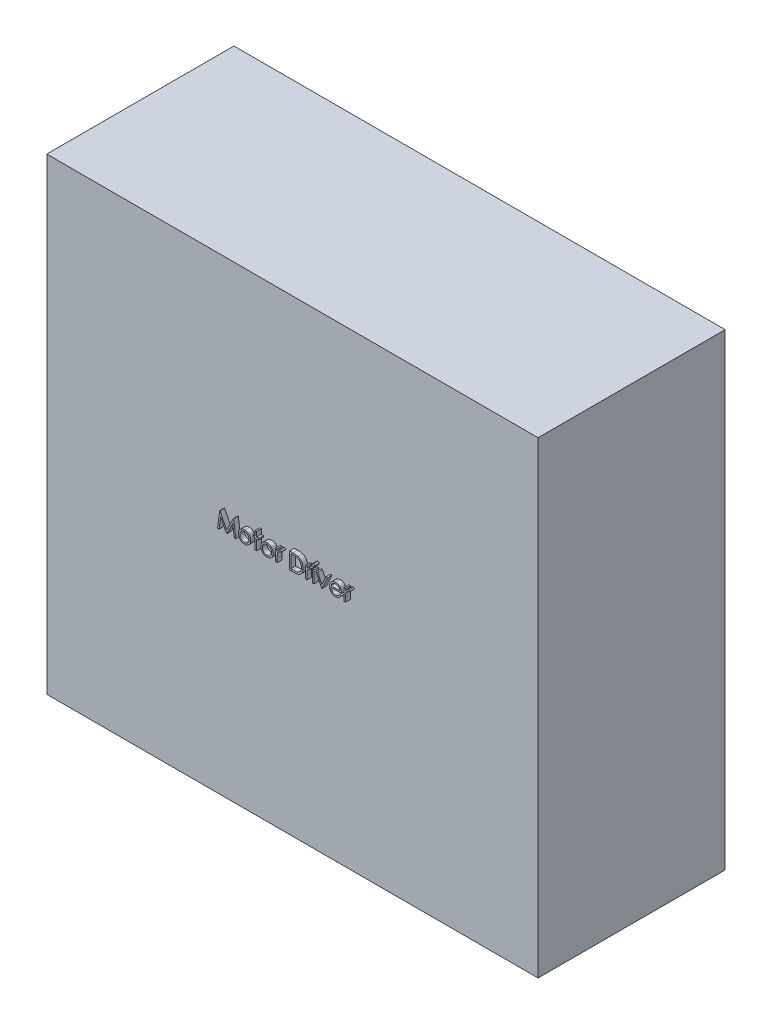
from build123d import *

# Parameters (mm, degrees)
SKETCH1_W           = 105
SKETCH1_H           = 100
BOSS_EXTRUDE1_DEPTH = 40
SKETCH6_W           = 0.314102564
SKETCH6_H           = 2.557692308
BOSS_EXTRUDE2_DEPTH = 1


with BuildPart() as part:
    # Sketch1 → Boss-Extrude1 (new body)
    with BuildSketch(Plane.XY):
        Rectangle(SKETCH1_W, SKETCH1_H)
    extrude(amount=BOSS_EXTRUDE1_DEPTH)

    # Sketch6 → Boss-Extrude2 (add)
    with BuildSketch(Plane.XY.offset(40)):
        Polygon((-14.999928936, -0.016220885), (-14.537889673, 3.483779115), (-14.493017878, 3.483779115), (-13.048005859, 0.611984244), (-11.606499449, 3.483779115), (-11.560926532, 3.483779115), (-11.096082782, -0.016220885), (-11.41158759, -0.016220885), (-11.746723808, 2.502208603), (-13.010145282, -0.016220885), (-13.080958583, -0.016220885), (-14.34928791, 2.507817577), (-14.683723006, -0.016220885), align=None)
        with BuildLine():
            add(Edge.make_bspline(
                [(-9.232501051, 2.586343218), (-9.184509779, 2.585321327), (-9.090410621, 2.583317648), (-8.952602735, 2.561902682), (-8.821057599, 2.529155318), (-8.695271407, 2.483883756), (-8.576855112, 2.423201805), (-8.464083867, 2.350792514), (-8.357266859, 2.265009921), (-8.293243829, 2.198651852), (-8.260746244, 2.164969019)],
                knots=[0, 0, 0, 0, 0.000143868, 0.000282091, 0.000417278, 0.000550139, 0.000682145, 0.000815559, 0.000951665, 0.001091969, 0.001091969, 0.001091969, 0.001091969], degree=3))
            add(Edge.make_bspline(
                [(-8.260746244, 2.164969019), (-8.23276429, 2.132755033), (-8.177341909, 2.068950491), (-8.106276191, 1.965494878), (-8.04505463, 1.858354778), (-7.995991669, 1.746107451), (-7.957306646, 1.62973278), (-7.929840949, 1.508830769), (-7.913504015, 1.383668421), (-7.911301048, 1.298664583), (-7.910185346, 1.255614051)],
                knots=[0, 0, 0, 0, 0.000127922, 0.000253368, 0.000375813, 0.000497617, 0.000620225, 0.000743195, 0.000869033, 0.000998161, 0.000998161, 0.000998161, 0.000998161], degree=3))
            add(Edge.make_bspline(
                [(-7.910185346, 1.255614051), (-7.911166684, 1.212313994), (-7.913105852, 1.12675106), (-7.931449468, 1.000731694), (-7.959980554, 0.878536872), (-8.000812392, 0.760678178), (-8.053170502, 0.646795351), (-8.117061189, 0.537385801), (-8.192932806, 0.432233668), (-8.278936803, 0.33223183), (-8.373988679, 0.240065615), (-8.477104827, 0.159737345), (-8.586258861, 0.090915821), (-8.702902215, 0.035479405), (-8.825969701, -0.008230295), (-8.955726769, -0.038930311), (-9.09197184, -0.057491995), (-9.184999061, -0.059875568), (-9.232501051, -0.06109268)],
                knots=[0, 0, 0, 0, 0.000129829, 0.000256548, 0.000381202, 0.000505812, 0.000630045, 0.000756669, 0.000885282, 0.001018518, 0.001151902, 0.001281775, 0.001409974, 0.001538236, 0.001668405, 0.001801048, 0.001937587, 0.002080055, 0.002080055, 0.002080055, 0.002080055], degree=3))
            add(Edge.make_bspline(
                [(-9.232501051, -0.06109268), (-9.280235771, -0.059871483), (-9.373726631, -0.057479709), (-9.510452613, -0.039002426), (-9.640442231, -0.008244444), (-9.76367083, 0.035623049), (-9.880815677, 0.090917593), (-9.990602174, 0.159529283), (-10.093802089, 0.240089438), (-10.188874074, 0.332225375), (-10.274872679, 0.432235331), (-10.350745687, 0.53738537), (-10.414636014, 0.646795463), (-10.466994218, 0.760678148), (-10.50782603, 0.87853688), (-10.536357123, 1.000731692), (-10.554700738, 1.126751061), (-10.556639906, 1.212313994), (-10.557621244, 1.255614051)],
                knots=[0, 0, 0, 0, 0.000143168, 0.000280402, 0.000413045, 0.000543214, 0.000672108, 0.000800903, 0.000930775, 0.00106416, 0.001197395, 0.001326009, 0.001452632, 0.001576866, 0.001701476, 0.00182613, 0.001952849, 0.002082678, 0.002082678, 0.002082678, 0.002082678], degree=3))
            add(Edge.make_bspline(
                [(-10.557621244, 1.255614051), (-10.556497933, 1.298430597), (-10.554273972, 1.3832), (-10.537953463, 1.50812706), (-10.510594906, 1.628824449), (-10.47186351, 1.744749925), (-10.422348319, 1.856505361), (-10.361987031, 1.963910192), (-10.290196398, 2.066897993), (-10.234994447, 2.130620073), (-10.207060346, 2.162865654)],
                knots=[0, 0, 0, 0, 0.000128428, 0.000254265, 0.000377235, 0.000499178, 0.000620341, 0.000743397, 0.000868267, 0.000996189, 0.000996189, 0.000996189, 0.000996189], degree=3))
            add(Edge.make_bspline(
                [(-10.207060346, 2.162865654), (-10.174611755, 2.196840593), (-10.110795891, 2.263658289), (-10.003447164, 2.349190813), (-9.890953343, 2.423106887), (-9.771228416, 2.482583103), (-9.645545558, 2.52942162), (-9.513326316, 2.561987135), (-9.3750508, 2.58324049), (-9.280491179, 2.585298668), (-9.232501051, 2.586343218)],
                knots=[0, 0, 0, 0, 0.000140798, 0.000276904, 0.000410699, 0.000543958, 0.000677061, 0.000812248, 0.000951858, 0.001095726, 0.001095726, 0.001095726, 0.001095726], degree=3))
        make_face()
        with BuildLine():
            add(Edge.make_bspline(
                [(-9.233903295, 2.272240654), (-9.267840906, 2.271276062), (-9.334840035, 2.26937178), (-9.43345962, 2.254887875), (-9.528399774, 2.231940371), (-9.619840618, 2.199336315), (-9.70747379, 2.157237416), (-9.791383193, 2.105529055), (-9.871815632, 2.044896099), (-9.947197696, 1.975433427), (-10.016380008, 1.899554433), (-10.076857985, 1.818706074), (-10.128283091, 1.734199728), (-10.17112325, 1.645947516), (-10.203030438, 1.553055103), (-10.22620346, 1.456574471), (-10.240673701, 1.356309055), (-10.24256008, 1.288148037), (-10.24351868, 1.253510686)],
                knots=[0, 0, 0, 0, 0.000101781, 0.000200935, 0.000298373, 0.000394396, 0.000491609, 0.000589491, 0.000689611, 0.000793323, 0.000896562, 0.000997243, 0.001095722, 0.001192936, 0.001290943, 0.001389744, 0.001490285, 0.001594167, 0.001594167, 0.001594167, 0.001594167], degree=3))
            add(Edge.make_bspline(
                [(-10.24351868, 1.253510686), (-10.241911856, 1.208758659), (-10.238722611, 1.119934253), (-10.212787375, 0.989123131), (-10.169401095, 0.863541278), (-10.110813815, 0.743924892), (-10.037407597, 0.633252614), (-9.95092053, 0.53458113), (-9.85228083, 0.449395319), (-9.74266433, 0.378714473), (-9.624310012, 0.322554717), (-9.499053691, 0.282755742), (-9.368412996, 0.256884049), (-9.279132265, 0.254312575), (-9.233903295, 0.253009885)],
                knots=[0, 0, 0, 0, 0.000134178, 0.000266319, 0.000398243, 0.00053182, 0.000664828, 0.000795487, 0.000924236, 0.001054533, 0.001185628, 0.001316003, 0.001448011, 0.001583547, 0.001583547, 0.001583547, 0.001583547], degree=3))
            add(Edge.make_bspline(
                [(-9.233903295, 0.253009885), (-9.188676926, 0.254320165), (-9.09940133, 0.256906622), (-8.968942153, 0.282625441), (-8.844028181, 0.322729102), (-8.725796794, 0.378651312), (-8.61623019, 0.449663727), (-8.516881069, 0.534100104), (-8.431132458, 0.633513955), (-8.357798853, 0.744071484), (-8.29825211, 0.863355836), (-8.255068909, 0.989146308), (-8.229071323, 1.11992835), (-8.225890494, 1.208756681), (-8.22428791, 1.253510686)],
                knots=[0, 0, 0, 0, 0.000135536, 0.000267545, 0.000397252, 0.000528347, 0.000658644, 0.000787925, 0.000918122, 0.00105113, 0.001185017, 0.001316942, 0.001449082, 0.00158326, 0.00158326, 0.00158326, 0.00158326], degree=3))
            add(Edge.make_bspline(
                [(-8.22428791, 1.253510686), (-8.22524618, 1.288148244), (-8.227131909, 1.356309669), (-8.241606874, 1.456572123), (-8.264762414, 1.553063719), (-8.296734031, 1.645915723), (-8.339388045, 1.734428227), (-8.391804838, 1.818457954), (-8.452035863, 1.8998345), (-8.522052984, 1.975188141), (-8.597356362, 2.044923178), (-8.6778214, 2.105552567), (-8.761606379, 2.157010162), (-8.848984961, 2.199696403), (-8.940437529, 2.231643743), (-9.035244658, 2.255020375), (-9.133443468, 2.269310571), (-9.200202511, 2.271257713), (-9.233903295, 2.272240654)],
                knots=[0, 0, 0, 0, 0.000103882, 0.000204424, 0.000303225, 0.000401232, 0.000498445, 0.000597291, 0.000697972, 0.000801684, 0.000905395, 0.001005516, 0.001103397, 0.001199979, 0.001296663, 0.00139342, 0.001492573, 0.001593654, 0.001593654, 0.001593654, 0.001593654], degree=3))
        make_face(mode=Mode.SUBTRACT)
        Polygon((-6.967877654, 3.573522705), (-6.65377509, 3.573522705), (-6.65377509, 2.541471423), (-6.205057141, 2.541471423), (-6.205057141, 2.227368859), (-6.65377509, 2.227368859), (-6.65377509, -0.016220885), (-6.967877654, -0.016220885), (-6.967877654, 2.227368859), (-7.416595603, 2.227368859), (-7.416595603, 2.541471423), (-6.967877654, 2.541471423), align=None)
        with BuildLine():
            add(Edge.make_bspline(
                [(-4.431219, 2.586343218), (-4.383227727, 2.585321327), (-4.28912857, 2.583317648), (-4.151320684, 2.561902682), (-4.019775548, 2.529155318), (-3.893989356, 2.483883756), (-3.77557306, 2.423201805), (-3.662801816, 2.350792514), (-3.555984807, 2.265009921), (-3.491961778, 2.198651852), (-3.459464192, 2.164969019)],
                knots=[0, 0, 0, 0, 0.000143868, 0.000282091, 0.000417278, 0.000550139, 0.000682145, 0.000815559, 0.000951665, 0.001091969, 0.001091969, 0.001091969, 0.001091969], degree=3))
            add(Edge.make_bspline(
                [(-3.459464192, 2.164969019), (-3.431482238, 2.132755033), (-3.376059858, 2.068950491), (-3.304994139, 1.965494878), (-3.243772579, 1.858354778), (-3.194709618, 1.746107451), (-3.156024594, 1.62973278), (-3.128558898, 1.508830769), (-3.112221963, 1.383668421), (-3.110018996, 1.298664583), (-3.108903295, 1.255614051)],
                knots=[0, 0, 0, 0, 0.000127922, 0.000253368, 0.000375813, 0.000497617, 0.000620225, 0.000743195, 0.000869033, 0.000998161, 0.000998161, 0.000998161, 0.000998161], degree=3))
            add(Edge.make_bspline(
                [(-3.108903295, 1.255614051), (-3.109884632, 1.212313994), (-3.111823801, 1.12675106), (-3.130167417, 1.000731694), (-3.158698503, 0.878536872), (-3.199530341, 0.760678178), (-3.25188845, 0.646795351), (-3.315779138, 0.537385801), (-3.391650755, 0.432233668), (-3.477654752, 0.33223183), (-3.572706628, 0.240065615), (-3.675822776, 0.159737345), (-3.78497681, 0.090915821), (-3.901620163, 0.035479405), (-4.02468765, -0.008230295), (-4.154444718, -0.038930311), (-4.290689788, -0.057491995), (-4.38371701, -0.059875568), (-4.431219, -0.06109268)],
                knots=[0, 0, 0, 0, 0.000129829, 0.000256548, 0.000381202, 0.000505812, 0.000630045, 0.000756669, 0.000885282, 0.001018518, 0.001151902, 0.001281775, 0.001409974, 0.001538236, 0.001668405, 0.001801048, 0.001937587, 0.002080055, 0.002080055, 0.002080055, 0.002080055], degree=3))
            add(Edge.make_bspline(
                [(-4.431219, -0.06109268), (-4.47895372, -0.059871483), (-4.572444579, -0.057479709), (-4.709170561, -0.039002426), (-4.83916018, -0.008244444), (-4.962388779, 0.035623049), (-5.079533626, 0.090917593), (-5.189320123, 0.159529283), (-5.292520038, 0.240089438), (-5.387592023, 0.332225375), (-5.473590628, 0.432235331), (-5.549463636, 0.53738537), (-5.613353962, 0.646795463), (-5.665712166, 0.760678148), (-5.706543979, 0.87853688), (-5.735075072, 1.000731692), (-5.753418686, 1.126751061), (-5.755357855, 1.212313994), (-5.756339192, 1.255614051)],
                knots=[0, 0, 0, 0, 0.000143168, 0.000280402, 0.000413045, 0.000543214, 0.000672108, 0.000800903, 0.000930775, 0.00106416, 0.001197395, 0.001326009, 0.001452632, 0.001576866, 0.001701476, 0.00182613, 0.001952849, 0.002082678, 0.002082678, 0.002082678, 0.002082678], degree=3))
            add(Edge.make_bspline(
                [(-5.756339192, 1.255614051), (-5.755215882, 1.298430597), (-5.752991921, 1.3832), (-5.736671412, 1.50812706), (-5.709312855, 1.628824449), (-5.670581459, 1.744749925), (-5.621066268, 1.856505361), (-5.56070498, 1.963910192), (-5.488914347, 2.066897993), (-5.433712396, 2.130620073), (-5.405778295, 2.162865654)],
                knots=[0, 0, 0, 0, 0.000128428, 0.000254265, 0.000377235, 0.000499178, 0.000620341, 0.000743397, 0.000868267, 0.000996189, 0.000996189, 0.000996189, 0.000996189], degree=3))
            add(Edge.make_bspline(
                [(-5.405778295, 2.162865654), (-5.373329704, 2.196840593), (-5.30951384, 2.263658289), (-5.202165112, 2.349190813), (-5.089671291, 2.423106887), (-4.969946365, 2.482583103), (-4.844263507, 2.52942162), (-4.712044265, 2.561987135), (-4.573768749, 2.58324049), (-4.479209128, 2.585298668), (-4.431219, 2.586343218)],
                knots=[0, 0, 0, 0, 0.000140798, 0.000276904, 0.000410699, 0.000543958, 0.000677061, 0.000812248, 0.000951858, 0.001095726, 0.001095726, 0.001095726, 0.001095726], degree=3))
        make_face()
        with BuildLine():
            add(Edge.make_bspline(
                [(-4.432621244, 2.272240654), (-4.466558855, 2.271276062), (-4.533557984, 2.26937178), (-4.632177568, 2.254887875), (-4.727117722, 2.231940371), (-4.818558566, 2.199336315), (-4.906191739, 2.157237416), (-4.990101141, 2.105529055), (-5.070533581, 2.044896099), (-5.145915645, 1.975433427), (-5.215097957, 1.899554433), (-5.275575933, 1.818706074), (-5.32700104, 1.734199728), (-5.369841199, 1.645947516), (-5.401748387, 1.553055103), (-5.424921409, 1.456574471), (-5.43939165, 1.356309055), (-5.441278028, 1.288148037), (-5.442236628, 1.253510686)],
                knots=[0, 0, 0, 0, 0.000101781, 0.000200935, 0.000298373, 0.000394396, 0.000491609, 0.000589491, 0.000689611, 0.000793323, 0.000896562, 0.000997243, 0.001095722, 0.001192936, 0.001290943, 0.001389744, 0.001490285, 0.001594167, 0.001594167, 0.001594167, 0.001594167], degree=3))
            add(Edge.make_bspline(
                [(-5.442236628, 1.253510686), (-5.440629805, 1.208758659), (-5.43744056, 1.119934253), (-5.411505324, 0.989123131), (-5.368119044, 0.863541278), (-5.309531764, 0.743924892), (-5.236125545, 0.633252614), (-5.149638479, 0.53458113), (-5.050998778, 0.449395319), (-4.941382278, 0.378714473), (-4.82302796, 0.322554717), (-4.697771639, 0.282755742), (-4.567130945, 0.256884049), (-4.477850214, 0.254312575), (-4.432621244, 0.253009885)],
                knots=[0, 0, 0, 0, 0.000134178, 0.000266319, 0.000398243, 0.00053182, 0.000664828, 0.000795487, 0.000924236, 0.001054533, 0.001185628, 0.001316003, 0.001448011, 0.001583547, 0.001583547, 0.001583547, 0.001583547], degree=3))
            add(Edge.make_bspline(
                [(-4.432621244, 0.253009885), (-4.387394875, 0.254320165), (-4.298119279, 0.256906622), (-4.167660102, 0.282625441), (-4.04274613, 0.322729102), (-3.924514743, 0.378651312), (-3.814948139, 0.449663727), (-3.715599018, 0.534100104), (-3.629850407, 0.633513955), (-3.556516802, 0.744071484), (-3.496970059, 0.863355836), (-3.453786857, 0.989146308), (-3.427789271, 1.11992835), (-3.424608443, 1.208756681), (-3.423005859, 1.253510686)],
                knots=[0, 0, 0, 0, 0.000135536, 0.000267545, 0.000397252, 0.000528347, 0.000658644, 0.000787925, 0.000918122, 0.00105113, 0.001185017, 0.001316942, 0.001449082, 0.00158326, 0.00158326, 0.00158326, 0.00158326], degree=3))
            add(Edge.make_bspline(
                [(-3.423005859, 1.253510686), (-3.423964129, 1.288148244), (-3.425849858, 1.356309669), (-3.440324823, 1.456572123), (-3.463480362, 1.553063719), (-3.495451979, 1.645915723), (-3.538105993, 1.734428227), (-3.590522786, 1.818457954), (-3.650753812, 1.8998345), (-3.720770933, 1.975188141), (-3.796074311, 2.044923178), (-3.876539349, 2.105552567), (-3.960324327, 2.157010162), (-4.04770291, 2.199696403), (-4.139155478, 2.231643743), (-4.233962607, 2.255020375), (-4.332161417, 2.269310571), (-4.39892046, 2.271257713), (-4.432621244, 2.272240654)],
                knots=[0, 0, 0, 0, 0.000103882, 0.000204424, 0.000303225, 0.000401232, 0.000498445, 0.000597291, 0.000697972, 0.000801684, 0.000905395, 0.001005516, 0.001103397, 0.001199979, 0.001296663, 0.00139342, 0.001492573, 0.001593654, 0.001593654, 0.001593654, 0.001593654], degree=3))
        make_face(mode=Mode.SUBTRACT)
        with BuildLine():
            Line((-2.570441756, 2.541471423), (-2.256339192, 2.541471423))
            Line((-2.256339192, 2.541471423), (-2.256339192, 2.164969019))
            add(Edge.make_bspline(
                [(-2.256339192, 2.164969019), (-2.233150434, 2.200024847), (-2.188802113, 2.267068847), (-2.115089183, 2.355738148), (-2.039585852, 2.429153194), (-1.961930665, 2.487656713), (-1.881552565, 2.531469832), (-1.800215613, 2.563562867), (-1.716640143, 2.582540182), (-1.660478219, 2.585073841), (-1.632340795, 2.586343218)],
                knots=[0, 0, 0, 0, 0.000126023, 0.000241017, 0.000345147, 0.000441342, 0.00053171, 0.000618946, 0.000702978, 0.000787349, 0.000787349, 0.000787349, 0.000787349], degree=3))
            add(Edge.make_bspline(
                [(-1.632340795, 2.586343218), (-1.610514468, 2.585152691), (-1.565605383, 2.582703105), (-1.497622793, 2.565492281), (-1.427579342, 2.538014258), (-1.382436954, 2.512174036), (-1.358903295, 2.498702994)],
                knots=[0, 0, 0, 0, 6.5445e-05, 0.000134658, 0.00020926, 0.000290509, 0.000290509, 0.000290509, 0.000290509], degree=3))
            Line((-1.358903295, 2.498702994), (-1.531379256, 2.226667737))
            add(Edge.make_bspline(
                [(-1.531379256, 2.226667737), (-1.546488278, 2.233408003), (-1.575168092, 2.246202319), (-1.617122658, 2.261344329), (-1.655803995, 2.270260245), (-1.680447554, 2.271610962), (-1.691936148, 2.272240654)],
                knots=[0, 0, 0, 0, 4.9621e-05, 9.4191e-05, 0.00013366, 0.000168129, 0.000168129, 0.000168129, 0.000168129], degree=3))
            add(Edge.make_bspline(
                [(-1.691936148, 2.272240654), (-1.717141881, 2.270560616), (-1.768554271, 2.267133827), (-1.84403877, 2.240195019), (-1.917285976, 2.196669779), (-1.975457638, 2.148398667), (-2.020499891, 2.10185087), (-2.052640117, 2.061202467), (-2.082122864, 2.015623836), (-2.110293084, 1.965894152), (-2.135959378, 1.911164306), (-2.159914047, 1.851981093), (-2.18157291, 1.788275964), (-2.193923155, 1.743893444), (-2.200249449, 1.721158923)],
                knots=[0, 0, 0, 0, 7.549e-05, 0.000153978, 0.000237553, 0.000330197, 0.000379784, 0.000431685, 0.000485357, 0.000542493, 0.000603021, 0.000666557, 0.00073396, 0.000804745, 0.000804745, 0.000804745, 0.000804745], degree=3))
            add(Edge.make_bspline(
                [(-2.200249449, 1.721158923), (-2.204981842, 1.700881749), (-2.215463734, 1.655969351), (-2.225655272, 1.580620826), (-2.23572479, 1.491597167), (-2.242821408, 1.388650574), (-2.24939945, 1.272038131), (-2.253109532, 1.141582185), (-2.256212673, 0.997148834), (-2.25629574, 0.896174481), (-2.256339192, 0.843354436)],
                knots=[0, 0, 0, 0, 6.2435e-05, 0.000138289, 0.000227871, 0.000331224, 0.000447781, 0.000578258, 0.000722716, 0.000881171, 0.000881171, 0.000881171, 0.000881171], degree=3))
            Line((-2.256339192, 0.843354436), (-2.256339192, -0.016220885))
            Line((-2.256339192, -0.016220885), (-2.570441756, -0.016220885))
            Line((-2.570441756, -0.016220885), (-2.570441756, 2.541471423))
        make_face()
        with BuildLine():
            Line((0.391096705, -0.016220885), (0.391096705, 3.483779115))
            Line((0.391096705, 3.483779115), (1.097827474, 3.483779115))
            add(Edge.make_bspline(
                [(1.097827474, 3.483779115), (1.159296462, 3.483336545), (1.278054228, 3.482481502), (1.449666675, 3.477060111), (1.608450438, 3.467469645), (1.753883297, 3.453500119), (1.886364509, 3.436347086), (2.005523117, 3.414846681), (2.11197526, 3.389458511), (2.1774447, 3.367813061), (2.208404397, 3.357577192)],
                knots=[0, 0, 0, 0, 0.000184407, 0.000356273, 0.000515031, 0.000661537, 0.000794508, 0.000915664, 0.001024665, 0.001122454, 0.001122454, 0.001122454, 0.001122454], degree=3))
            add(Edge.make_bspline(
                [(2.208404397, 3.357577192), (2.248899137, 3.342146487), (2.328970329, 3.311634993), (2.442977452, 3.254078691), (2.550302814, 3.188865589), (2.651521959, 3.115909727), (2.744322786, 3.033145378), (2.832330682, 2.944088293), (2.911945406, 2.845499952), (2.984853702, 2.739424964), (3.050589362, 2.627112912), (3.10772852, 2.508777804), (3.155182513, 2.385020595), (3.19457574, 2.256185447), (3.225622197, 2.12198907), (3.246804129, 1.982275204), (3.260775119, 1.837596014), (3.26217917, 1.73942155), (3.262891577, 1.689608442)],
                knots=[0, 0, 0, 0, 0.000129935, 0.000256923, 0.000382457, 0.000506429, 0.000630624, 0.000755071, 0.000881654, 0.001010204, 0.001140916, 0.00127168, 0.001403968, 0.001538146, 0.001675568, 0.001816774, 0.001961818, 0.002111216, 0.002111216, 0.002111216, 0.002111216], degree=3))
            add(Edge.make_bspline(
                [(3.262891577, 1.689608442), (3.262262609, 1.646347204), (3.261023163, 1.561096415), (3.249893847, 1.435455519), (3.233717527, 1.313541948), (3.208673329, 1.195936248), (3.178270816, 1.08160803), (3.139306665, 0.971775786), (3.094671169, 0.865431976), (3.04262129, 0.7640145), (2.985479905, 0.667931128), (2.924158162, 0.5773556), (2.858721466, 0.493580378), (2.788545834, 0.416351766), (2.714538117, 0.345786188), (2.636213787, 0.281294172), (2.553370736, 0.224137617), (2.466380013, 0.172070509), (2.372703884, 0.126650154), (2.270568018, 0.088220144), (2.15953684, 0.056373529), (2.039882883, 0.029802633), (1.911399405, 0.00872533), (1.773960439, -0.005401062), (1.627777149, -0.014953995), (1.527397884, -0.015790388), (1.475732122, -0.016220885)],
                knots=[0, 0, 0, 0, 0.000129755, 0.000255696, 0.000378151, 0.000498469, 0.000616165, 0.000732801, 0.000847787, 0.000961923, 0.00107447, 0.001182981, 0.001289856, 0.001393094, 0.001495748, 0.001596383, 0.00169713, 0.001797413, 0.001900265, 0.002008995, 0.002124372, 0.002246504, 0.002376522, 0.002514729, 0.002660846, 0.00281582, 0.00281582, 0.00281582, 0.00281582], degree=3))
            Line((1.475732122, -0.016220885), (0.391096705, -0.016220885))
        make_face()
        with BuildLine():
            Line((0.705199269, 0.342753474), (1.106942058, 0.342753474))
            add(Edge.make_bspline(
                [(1.106942058, 0.342753474), (1.164670428, 0.343001571), (1.275703227, 0.343478751), (1.435361224, 0.347665954), (1.581240621, 0.354507891), (1.71336213, 0.364082969), (1.831651154, 0.376751584), (1.936354904, 0.390876487), (2.027130162, 0.408473938), (2.082059599, 0.424424897), (2.107442859, 0.431795942)],
                knots=[0, 0, 0, 0, 0.000173183, 0.000333094, 0.000479096, 0.000611272, 0.000730431, 0.000835931, 0.000928194, 0.001007458, 0.001007458, 0.001007458, 0.001007458], degree=3))
            add(Edge.make_bspline(
                [(2.107442859, 0.431795942), (2.139391221, 0.4430475), (2.202524859, 0.465281874), (2.293405944, 0.505839535), (2.378162949, 0.553881605), (2.458272974, 0.607283879), (2.53259963, 0.667929881), (2.602023746, 0.734500869), (2.666405547, 0.807335645), (2.725079855, 0.886343806), (2.777588159, 0.971033602), (2.823059389, 1.060572435), (2.86291092, 1.153979246), (2.894189513, 1.252688404), (2.918705097, 1.355817463), (2.936069785, 1.463373676), (2.94688451, 1.575336958), (2.948145958, 1.651489082), (2.948789013, 1.690309564)],
                knots=[0, 0, 0, 0, 0.000101593, 0.000200759, 0.000298073, 0.000393552, 0.000489254, 0.000585454, 0.000681817, 0.000780535, 0.000880346, 0.000980374, 0.001081551, 0.001184655, 0.001290601, 0.001399295, 0.001511268, 0.001627707, 0.001627707, 0.001627707, 0.001627707], degree=3))
            add(Edge.make_bspline(
                [(2.948789013, 1.690309564), (2.948275725, 1.731243044), (2.947267368, 1.811657229), (2.934593057, 1.929647924), (2.916071502, 2.043128575), (2.889287816, 2.15210677), (2.855156937, 2.256795122), (2.812562295, 2.356614632), (2.763895676, 2.452619501), (2.705992339, 2.542593867), (2.642576746, 2.627686976), (2.572198866, 2.705641892), (2.495976828, 2.776636192), (2.414741978, 2.841775505), (2.326204879, 2.89843918), (2.232451188, 2.949125862), (2.132105517, 2.992141753), (2.062292821, 3.015020616), (2.026813852, 3.026647705)],
                knots=[0, 0, 0, 0, 0.000122746, 0.000241136, 0.000355593, 0.000467485, 0.000577457, 0.000685538, 0.00079278, 0.000899951, 0.001006101, 0.00111085, 0.001214524, 0.001318328, 0.001422759, 0.001529413, 0.00163777, 0.001749741, 0.001749741, 0.001749741, 0.001749741], degree=3))
            add(Edge.make_bspline(
                [(2.026813852, 3.026647705), (1.997462706, 3.034764133), (1.935054116, 3.052021886), (1.833214652, 3.070847258), (1.718599502, 3.087451757), (1.590699801, 3.101509796), (1.449661342, 3.111597118), (1.295375654, 3.119168432), (1.12777605, 3.124275065), (1.011593516, 3.124623772), (0.951293019, 3.124804756)],
                knots=[0, 0, 0, 0, 9.1321e-05, 0.000194173, 0.000310382, 0.000438754, 0.000580072, 0.000734511, 0.000902151, 0.001083046, 0.001083046, 0.001083046, 0.001083046], degree=3))
            Line((0.951293019, 3.124804756), (0.705199269, 3.124804756))
            Line((0.705199269, 3.124804756), (0.705199269, 0.342753474))
        make_face(mode=Mode.SUBTRACT)
        with BuildLine():
            Line((3.801353115, 2.541471423), (4.115455679, 2.541471423))
            Line((4.115455679, 2.541471423), (4.115455679, 2.164969019))
            add(Edge.make_bspline(
                [(4.115455679, 2.164969019), (4.138644438, 2.200024847), (4.182992759, 2.267068847), (4.256705688, 2.355738148), (4.33220902, 2.429153194), (4.409864207, 2.487656713), (4.490242307, 2.531469832), (4.571579259, 2.563562867), (4.655154729, 2.582540182), (4.711316653, 2.585073841), (4.739454077, 2.586343218)],
                knots=[0, 0, 0, 0, 0.000126023, 0.000241017, 0.000345147, 0.000441342, 0.00053171, 0.000618946, 0.000702978, 0.000787349, 0.000787349, 0.000787349, 0.000787349], degree=3))
            add(Edge.make_bspline(
                [(4.739454077, 2.586343218), (4.761280403, 2.585152691), (4.806189489, 2.582703105), (4.874172078, 2.565492281), (4.94421553, 2.538014258), (4.989357917, 2.512174036), (5.012891577, 2.498702994)],
                knots=[0, 0, 0, 0, 6.5445e-05, 0.000134658, 0.00020926, 0.000290509, 0.000290509, 0.000290509, 0.000290509], degree=3))
            Line((5.012891577, 2.498702994), (4.840415615, 2.226667737))
            add(Edge.make_bspline(
                [(4.840415615, 2.226667737), (4.825306594, 2.233408003), (4.79662678, 2.246202319), (4.754672213, 2.261344329), (4.715990877, 2.270260245), (4.691347318, 2.271610962), (4.679858724, 2.272240654)],
                knots=[0, 0, 0, 0, 4.9621e-05, 9.4191e-05, 0.00013366, 0.000168129, 0.000168129, 0.000168129, 0.000168129], degree=3))
            add(Edge.make_bspline(
                [(4.679858724, 2.272240654), (4.654652991, 2.270560616), (4.603240601, 2.267133827), (4.527756101, 2.240195019), (4.454508896, 2.196669779), (4.396337234, 2.148398667), (4.351294981, 2.10185087), (4.319154755, 2.061202467), (4.289672008, 2.015623836), (4.261501788, 1.965894152), (4.235835494, 1.911164306), (4.211880824, 1.851981093), (4.190221961, 1.788275964), (4.177871717, 1.743893444), (4.171545423, 1.721158923)],
                knots=[0, 0, 0, 0, 7.549e-05, 0.000153978, 0.000237553, 0.000330197, 0.000379784, 0.000431685, 0.000485357, 0.000542493, 0.000603021, 0.000666557, 0.00073396, 0.000804745, 0.000804745, 0.000804745, 0.000804745], degree=3))
            add(Edge.make_bspline(
                [(4.171545423, 1.721158923), (4.16681303, 1.700881749), (4.156331138, 1.655969351), (4.1461396, 1.580620826), (4.136070082, 1.491597167), (4.128973464, 1.388650574), (4.122395422, 1.272038131), (4.118685339, 1.141582185), (4.115582199, 0.997148834), (4.115499132, 0.896174481), (4.115455679, 0.843354436)],
                knots=[0, 0, 0, 0, 6.2435e-05, 0.000138289, 0.000227871, 0.000331224, 0.000447781, 0.000578258, 0.000722716, 0.000881171, 0.000881171, 0.000881171, 0.000881171], degree=3))
            Line((4.115455679, 0.843354436), (4.115455679, -0.016220885))
            Line((4.115455679, -0.016220885), (3.801353115, -0.016220885))
            Line((3.801353115, -0.016220885), (3.801353115, 2.541471423))
        make_face()
        with BuildLine():
            add(Edge.make_bspline(
                [(5.437771385, 3.6183945), (5.4572627, 3.617490348), (5.49543044, 3.615719844), (5.550623708, 3.600558366), (5.60088072, 3.574858681), (5.645458453, 3.540379), (5.683710339, 3.499829557), (5.71049105, 3.452568588), (5.727703446, 3.40150995), (5.729782001, 3.36589486), (5.730840295, 3.347761487)],
                knots=[0, 0, 0, 0, 5.84e-05, 0.000114358, 0.000170171, 0.000226684, 0.000282761, 0.000336156, 0.000388483, 0.00044276, 0.00044276, 0.00044276, 0.00044276], degree=3))
            add(Edge.make_bspline(
                [(5.730840295, 3.347761487), (5.729758135, 3.330098834), (5.727618833, 3.295181859), (5.710504345, 3.245008387), (5.683482107, 3.198404103), (5.645482981, 3.157933393), (5.60087422, 3.123472773), (5.550625434, 3.097768034), (5.495429986, 3.082607897), (5.457262547, 3.080837208), (5.437771385, 3.079932961)],
                knots=[0, 0, 0, 0, 5.2882e-05, 0.000104542, 0.000157332, 0.000213408, 0.000269922, 0.000325735, 0.000381693, 0.000440092, 0.000440092, 0.000440092, 0.000440092], degree=3))
            add(Edge.make_bspline(
                [(5.437771385, 3.079932961), (5.418503109, 3.080802682), (5.380999929, 3.082495478), (5.326633087, 3.098065496), (5.276804597, 3.123481569), (5.232139925, 3.157707754), (5.194909732, 3.198652652), (5.167811406, 3.244979946), (5.150736444, 3.2951891), (5.148591816, 3.330101266), (5.147506961, 3.347761487)],
                knots=[0, 0, 0, 0, 5.7701e-05, 0.000112308, 0.000168121, 0.000224634, 0.000280239, 0.000333029, 0.000384689, 0.000437571, 0.000437571, 0.000437571, 0.000437571], degree=3))
            add(Edge.make_bspline(
                [(5.147506961, 3.347761487), (5.148568048, 3.365892337), (5.150652089, 3.401502469), (5.167824205, 3.452597502), (5.194684013, 3.499579004), (5.232164577, 3.540604503), (5.276798037, 3.574849938), (5.326634782, 3.60026092), (5.380999481, 3.615832259), (5.418502957, 3.617524873), (5.437771385, 3.6183945)],
                knots=[0, 0, 0, 0, 5.4277e-05, 0.000106603, 0.000159999, 0.000215605, 0.000272118, 0.000327931, 0.000382538, 0.000440239, 0.000440239, 0.000440239, 0.000440239], degree=3))
        make_face()
        with Locations((5.439173628, 1.262625269)):
            Rectangle(SKETCH6_W, SKETCH6_H)
        Polygon((6.089814654, 2.541471423), (6.429858724, 2.541471423), (7.278917218, 0.679291936), (8.127975711, 2.541471423), (8.468019782, 2.541471423), (7.301353115, -0.016220885), (7.25648132, -0.016220885), align=None)
        with BuildLine():
            Line((11.105639974, 0.791471423), (11.384686449, 0.644936968))
            add(Edge.make_bspline(
                [(11.384686449, 0.644936968), (11.362449853, 0.605493637), (11.319186245, 0.528752534), (11.244785497, 0.423320673), (11.166793424, 0.328472957), (11.081689456, 0.246743303), (10.992019777, 0.175491918), (10.897287123, 0.113154094), (10.796998305, 0.060035573), (10.69114858, 0.015283045), (10.578849029, -0.019126449), (10.459827513, -0.04343067), (10.333856017, -0.058453938), (10.247509837, -0.060199079), (10.203296224, -0.06109268)],
                knots=[0, 0, 0, 0, 0.000135759, 0.000264133, 0.000386579, 0.000503597, 0.000617365, 0.000729763, 0.000843304, 0.000957371, 0.001074023, 0.001195027, 0.001321389, 0.001453992, 0.001453992, 0.001453992, 0.001453992], degree=3))
            add(Edge.make_bspline(
                [(10.203296224, -0.06109268), (10.154154247, -0.059945504), (10.058292485, -0.057707697), (9.918752738, -0.038415233), (9.78737332, -0.006942874), (9.664161616, 0.037022667), (9.549419364, 0.094449991), (9.442918509, 0.164409473), (9.344098983, 0.246541728), (9.256074774, 0.341558171), (9.176830891, 0.443240128), (9.106905071, 0.549196013), (9.04844764, 0.659159237), (9.00089503, 0.772429762), (8.962490165, 0.888293655), (8.935723461, 1.007805123), (8.920293713, 1.130640707), (8.917929268, 1.213738043), (8.916737731, 1.255614051)],
                knots=[0, 0, 0, 0, 0.000147371, 0.000287478, 0.000421649, 0.000552053, 0.000679042, 0.000805636, 0.000933558, 0.00106351, 0.001193382, 0.001319977, 0.001443869, 0.001566405, 0.001688128, 0.001809576, 0.001933238, 0.002058864, 0.002058864, 0.002058864, 0.002058864], degree=3))
            add(Edge.make_bspline(
                [(8.916737731, 1.255614051), (8.917796872, 1.294908882), (8.91989595, 1.372786046), (8.933126738, 1.488051591), (8.956575031, 1.600080043), (8.988751355, 1.708964491), (9.030302601, 1.814522625), (9.08113482, 1.916818689), (9.141327198, 2.015743829), (9.187799872, 2.078146963), (9.211208885, 2.109580397)],
                knots=[0, 0, 0, 0, 0.000117891, 0.000233644, 0.000347498, 0.000460856, 0.000573868, 0.000687374, 0.000803169, 0.000920699, 0.000920699, 0.000920699, 0.000920699], degree=3))
            add(Edge.make_bspline(
                [(9.211208885, 2.109580397), (9.242916567, 2.147449267), (9.305327514, 2.221987418), (9.410883869, 2.319925744), (9.525184066, 2.401969519), (9.646795692, 2.469976655), (9.777132166, 2.521650302), (9.914441457, 2.560157884), (10.060287043, 2.581735895), (10.159992264, 2.584783729), (10.211008564, 2.586343218)],
                knots=[0, 0, 0, 0, 0.000148071, 0.000291452, 0.00043058, 0.000569298, 0.000708346, 0.00085021, 0.000996268, 0.001149307, 0.001149307, 0.001149307, 0.001149307], degree=3))
            add(Edge.make_bspline(
                [(10.211008564, 2.586343218), (10.263456169, 2.584989169), (10.366346415, 2.582332834), (10.516378536, 2.5577065), (10.658339253, 2.518653946), (10.792171757, 2.463500155), (10.917889618, 2.392340603), (11.034675667, 2.304198762), (11.14452718, 2.201780675), (11.208435759, 2.123017465), (11.240956481, 2.082937769)],
                knots=[0, 0, 0, 0, 0.000157241, 0.00030847, 0.000454763, 0.000598116, 0.000741606, 0.000886879, 0.001036172, 0.001190853, 0.001190853, 0.001190853, 0.001190853], degree=3))
            add(Edge.make_bspline(
                [(11.240956481, 2.082937769), (11.263083419, 2.052734188), (11.307190012, 1.992528069), (11.362437112, 1.894356912), (11.410394507, 1.791646318), (11.448727468, 1.682736021), (11.479766969, 1.56891644), (11.502223788, 1.449373896), (11.515393407, 1.324143984), (11.517982104, 1.238817429), (11.519301833, 1.195317577)],
                knots=[0, 0, 0, 0, 0.000112234, 0.000223721, 0.000337279, 0.000451932, 0.000569628, 0.000690912, 0.000816421, 0.00094695, 0.00094695, 0.00094695, 0.00094695], degree=3))
            Line((11.519301833, 1.195317577), (9.230840295, 1.195317577))
            add(Edge.make_bspline(
                [(9.230840295, 1.195317577), (9.232379901, 1.161617113), (9.235407475, 1.095346509), (9.249522618, 0.998375726), (9.271771392, 0.906002384), (9.303040455, 0.818919342), (9.3409073, 0.735989214), (9.387293017, 0.657827177), (9.442632571, 0.584789247), (9.50435827, 0.51622211), (9.573065365, 0.455161348), (9.645348113, 0.400509572), (9.722241678, 0.354703975), (9.803139761, 0.317524086), (9.887911546, 0.28841777), (9.976583741, 0.268549949), (10.068981858, 0.255242842), (10.131967592, 0.253763177), (10.164033404, 0.253009885)],
                knots=[0, 0, 0, 0, 0.000101159, 0.000198924, 0.000293472, 0.000385722, 0.000476069, 0.000566611, 0.000657757, 0.000750573, 0.000842919, 0.000933083, 0.001022062, 0.001110842, 0.001199752, 0.001290403, 0.001383113, 0.001479259, 0.001479259, 0.001479259, 0.001479259], degree=3))
            add(Edge.make_bspline(
                [(10.164033404, 0.253009885), (10.195384551, 0.253617941), (10.257591242, 0.254824442), (10.3502321, 0.266556353), (10.441371627, 0.285526629), (10.53063261, 0.311416619), (10.616203456, 0.342993471), (10.695449006, 0.381096329), (10.768329222, 0.423246075), (10.836446188, 0.47145575), (10.902517182, 0.530463937), (10.968059668, 0.604099658), (11.038336322, 0.691187186), (11.082325914, 0.756732852), (11.105639974, 0.791471423)],
                knots=[0, 0, 0, 0, 9.4016e-05, 0.000186545, 0.000279636, 0.000373054, 0.000465125, 0.000552934, 0.000636508, 0.000717442, 0.000802858, 0.000901616, 0.001012865, 0.001138311, 0.001138311, 0.001138311, 0.001138311], degree=3))
        make_face()
        with BuildLine():
            add(Edge.make_bspline(
                [(11.205199269, 1.509420141), (11.193702645, 1.551083015), (11.171575343, 1.631270635), (11.125338979, 1.742311526), (11.073267438, 1.840999427), (11.011645707, 1.92657906), (10.941826981, 2.002582573), (10.861181798, 2.069001158), (10.770745905, 2.128418609), (10.670986764, 2.178571108), (10.565344979, 2.221260967), (10.454738787, 2.249886083), (10.341880999, 2.269495625), (10.265546713, 2.271321734), (10.227134365, 2.272240654)],
                knots=[0, 0, 0, 0, 0.000129543, 0.000249328, 0.000360065, 0.000463575, 0.000564789, 0.000668832, 0.000776175, 0.000888744, 0.001003316, 0.001117263, 0.001230914, 0.001346035, 0.001346035, 0.001346035, 0.001346035], degree=3))
            add(Edge.make_bspline(
                [(10.227134365, 2.272240654), (10.195784927, 2.271628982), (10.133813678, 2.270419836), (10.04251261, 2.258949707), (9.954832911, 2.239989862), (9.870127623, 2.214024905), (9.789506755, 2.179416303), (9.711311986, 2.138833076), (9.63753159, 2.089291492), (9.591390295, 2.051532638), (9.568079878, 2.032457)],
                knots=[0, 0, 0, 0, 9.4016e-05, 0.000185849, 0.000275511, 0.000362884, 0.000451173, 0.00053836, 0.000626838, 0.000717174, 0.000717174, 0.000717174, 0.000717174], degree=3))
            add(Edge.make_bspline(
                [(9.568079878, 2.032457), (9.551386596, 2.017362684), (9.517603462, 1.986815468), (9.47246294, 1.934186262), (9.429242468, 1.8774347), (9.389908815, 1.814389575), (9.353831229, 1.745768796), (9.320071251, 1.672151161), (9.289684839, 1.59297803), (9.272588729, 1.537805591), (9.263793019, 1.509420141)],
                knots=[0, 0, 0, 0, 6.7454e-05, 0.00013651, 0.000207604, 0.000281328, 0.000359112, 0.000440057, 0.000524171, 0.000613305, 0.000613305, 0.000613305, 0.000613305], degree=3))
            Line((9.263793019, 1.509420141), (11.205199269, 1.509420141))
        make_face(mode=Mode.SUBTRACT)
        with BuildLine():
            Line((12.057763372, 2.541471423), (12.371865936, 2.541471423))
            Line((12.371865936, 2.541471423), (12.371865936, 2.164969019))
            add(Edge.make_bspline(
                [(12.371865936, 2.164969019), (12.395054695, 2.200024847), (12.439403016, 2.267068847), (12.513115945, 2.355738148), (12.588619276, 2.429153194), (12.666274463, 2.487656713), (12.746652563, 2.531469832), (12.827989515, 2.563562867), (12.911564985, 2.582540182), (12.967726909, 2.585073841), (12.995864333, 2.586343218)],
                knots=[0, 0, 0, 0, 0.000126023, 0.000241017, 0.000345147, 0.000441342, 0.00053171, 0.000618946, 0.000702978, 0.000787349, 0.000787349, 0.000787349, 0.000787349], degree=3))
            add(Edge.make_bspline(
                [(12.995864333, 2.586343218), (13.01769066, 2.585152691), (13.062599745, 2.582703105), (13.130582335, 2.565492281), (13.200625787, 2.538014258), (13.245768174, 2.512174036), (13.269301833, 2.498702994)],
                knots=[0, 0, 0, 0, 6.5445e-05, 0.000134658, 0.00020926, 0.000290509, 0.000290509, 0.000290509, 0.000290509], degree=3))
            Line((13.269301833, 2.498702994), (13.096825872, 2.226667737))
            add(Edge.make_bspline(
                [(13.096825872, 2.226667737), (13.081716851, 2.233408003), (13.053037036, 2.246202319), (13.01108247, 2.261344329), (12.972401133, 2.270260245), (12.947757575, 2.271610962), (12.936268981, 2.272240654)],
                knots=[0, 0, 0, 0, 4.9621e-05, 9.4191e-05, 0.00013366, 0.000168129, 0.000168129, 0.000168129, 0.000168129], degree=3))
            add(Edge.make_bspline(
                [(12.936268981, 2.272240654), (12.911063247, 2.270560616), (12.859650857, 2.267133827), (12.784166358, 2.240195019), (12.710919152, 2.196669779), (12.65274749, 2.148398667), (12.607705237, 2.10185087), (12.575565012, 2.061202467), (12.546082265, 2.015623836), (12.517912044, 1.965894152), (12.49224575, 1.911164306), (12.468291081, 1.851981093), (12.446632218, 1.788275964), (12.434281974, 1.743893444), (12.427955679, 1.721158923)],
                knots=[0, 0, 0, 0, 7.549e-05, 0.000153978, 0.000237553, 0.000330197, 0.000379784, 0.000431685, 0.000485357, 0.000542493, 0.000603021, 0.000666557, 0.00073396, 0.000804745, 0.000804745, 0.000804745, 0.000804745], degree=3))
            add(Edge.make_bspline(
                [(12.427955679, 1.721158923), (12.423223286, 1.700881749), (12.412741394, 1.655969351), (12.402549856, 1.580620826), (12.392480339, 1.491597167), (12.38538372, 1.388650574), (12.378805678, 1.272038131), (12.375095596, 1.141582185), (12.371992455, 0.997148834), (12.371909388, 0.896174481), (12.371865936, 0.843354436)],
                knots=[0, 0, 0, 0, 6.2435e-05, 0.000138289, 0.000227871, 0.000331224, 0.000447781, 0.000578258, 0.000722716, 0.000881171, 0.000881171, 0.000881171, 0.000881171], degree=3))
            Line((12.371865936, 0.843354436), (12.371865936, -0.016220885))
            Line((12.371865936, -0.016220885), (12.057763372, -0.016220885))
            Line((12.057763372, -0.016220885), (12.057763372, 2.541471423))
        make_face()
    extrude(amount=BOSS_EXTRUDE2_DEPTH)


solid = part.part
